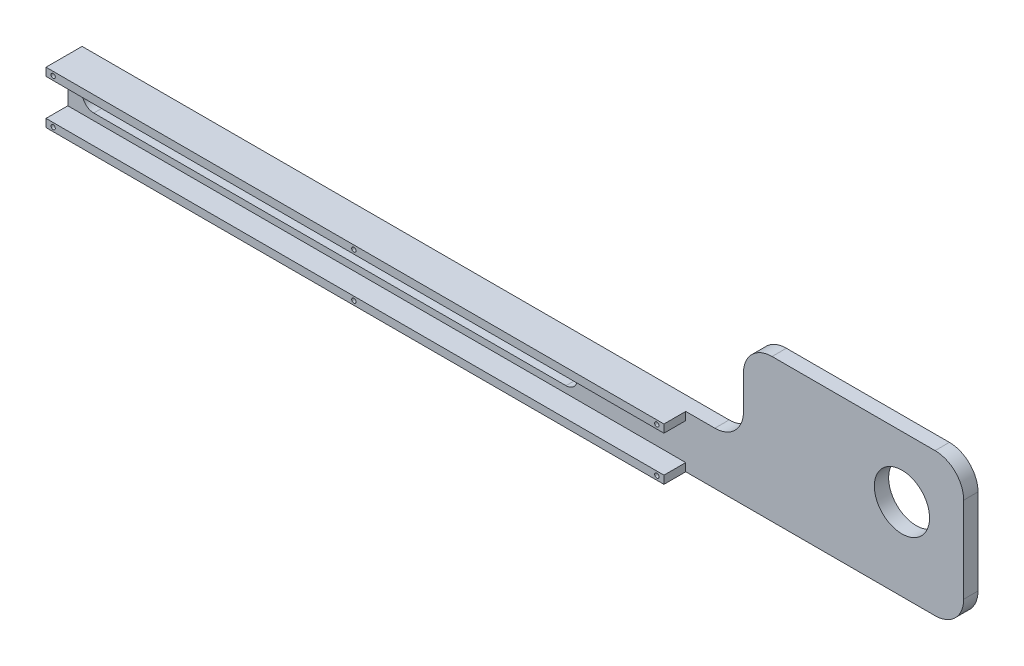
from build123d import *

# Parameters (mm, degrees)
SKETCH1_W           = 236.22
SKETCH1_H           = 18.288
SKETCH1_R           = 9.652
BOSS_EXTRUDE1_DEPTH = 5
FILLET1_R           = 10
SKETCH2_W           = 216.043861244
SKETCH2_H           = 2.794
BOSS_EXTRUDE2_DEPTH = 7.62
SKETCH3_R           = 0.75
CUT_EXTRUDE1_DEPTH  = 5


with BuildPart() as part:
    # Sketch1 → Boss-Extrude1 (new body)
    with BuildSketch(Plane.XY):
        with Locations((118.11, 9.144)):
            Rectangle(SKETCH1_W, SKETCH1_H)
        with BuildLine():
            ThreePointArc((174.18, 5.144), (178.18, 9.144), (174.18, 13.144))
            Line((174.18, 13.144), (9.08, 13.144))
            ThreePointArc((9.08, 13.144), (5.08, 9.144), (9.08, 5.144))
            Line((9.08, 5.144), (174.18, 5.144))
        make_face(mode=Mode.SUBTRACT)
        Polygon((236.22, 18.288), (236.22, 0), (313.22, 0), (313.22, 50), (236.22, 50), align=None)
        with Locations((291.63, 28.638)):
            Circle(SKETCH1_R, mode=Mode.SUBTRACT)
    extrude(amount=BOSS_EXTRUDE1_DEPTH)

    # Fillet1
    fillet1_edges = [part.edges().sort_by_distance(p)[0] for p in [
        (236.22, 18.288, 2.5),
        (236.22, 50, 2.5),
        (313.22, 50, 2.5),
        (313.22, 0, 2.5),
    ]]
    fillet(fillet1_edges, radius=FILLET1_R)

    # Sketch2 → Boss-Extrude2 (add)
    with BuildSketch(Plane.XY.offset(5)):
        with Locations((108.021930622, 16.891)):
            Rectangle(SKETCH2_W, SKETCH2_H)
        with Locations((108.021930622, 1.397)):
            Rectangle(SKETCH2_W, SKETCH2_H)
    extrude(amount=BOSS_EXTRUDE2_DEPTH)

    # Sketch3 → Cut-Extrude1 (cut)
    with BuildSketch(Plane.XY.offset(12.62)):
        with Locations((2.5, 16.891)):
            Circle(SKETCH3_R)
        with Locations((2.5, 1.397)):
            Circle(SKETCH3_R)
        with Locations((107.6321922, 16.891)):
            Circle(SKETCH3_R)
        with Locations((107.6321922, 1.397)):
            Circle(SKETCH3_R)
        with Locations((213.543861244, 16.891)):
            Circle(SKETCH3_R)
        with Locations((213.543861244, 1.397)):
            Circle(SKETCH3_R)
    extrude(amount=-CUT_EXTRUDE1_DEPTH, mode=Mode.SUBTRACT)


solid = part.part
